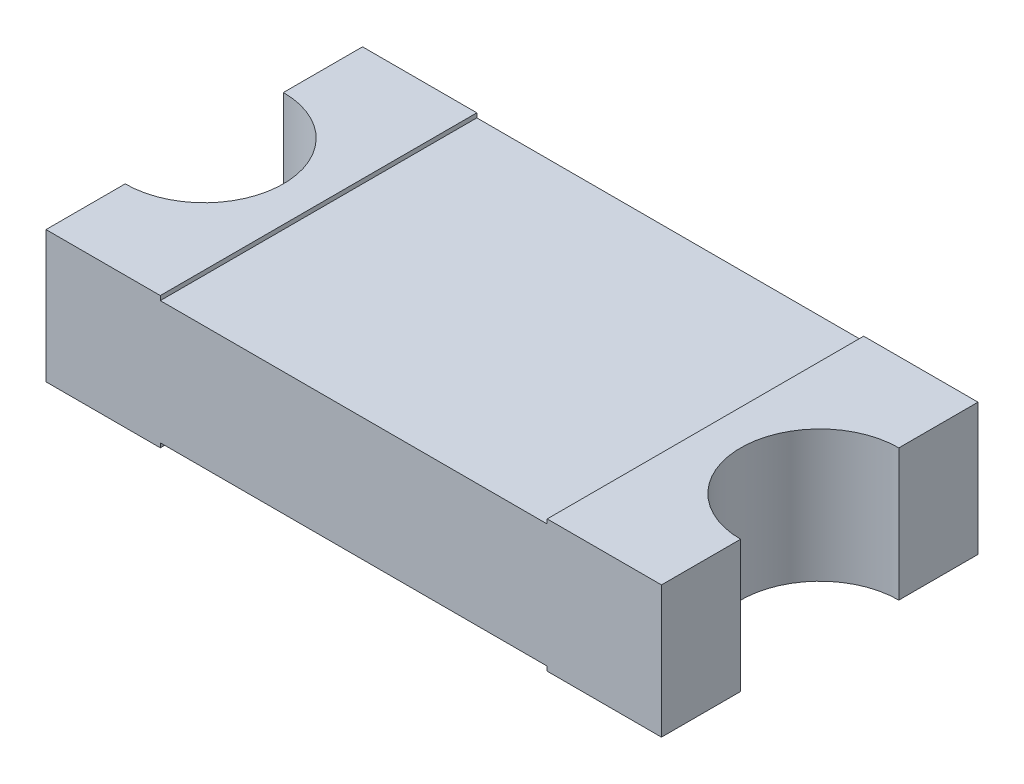
from build123d import *

# Parameters (mm, degrees)
BOSS_EXTRUDE1_DEPTH = 0.75
SKETCH2_W           = 2.2
SKETCH2_H           = 1.8
CUT_EXTRUDE1_DEPTH  = 0.025


with BuildPart() as part:
    # Sketch1 → Boss-Extrude1 (new body)
    with BuildSketch(Plane(origin=(0, 0, 0), x_dir=(1, 0, 0), z_dir=(0, 1, 0))):
        with BuildLine():
            Line((1.75, 0.45), (1.75, 0.9))
            Line((1.75, 0.9), (-1.75, 0.9))
            Line((-1.75, 0.9), (-1.75, 0.45))
            ThreePointArc((-1.75, 0.45), (-1.3, 0), (-1.75, -0.45))
            Line((-1.75, -0.45), (-1.75, -0.9))
            Line((-1.75, -0.9), (1.75, -0.9))
            Line((1.75, -0.9), (1.75, -0.45))
            ThreePointArc((1.75, -0.45), (1.3, 0), (1.75, 0.45))
        make_face()
    extrude(amount=BOSS_EXTRUDE1_DEPTH)

    # Sketch2 → Cut-Extrude1 (cut)
    with BuildSketch(Plane(origin=(0, 0.75, 0), x_dir=(1, 0, 0), z_dir=(0, 1, 0))):
        Rectangle(SKETCH2_W, SKETCH2_H)
    cut_extrude1 = extrude(amount=-CUT_EXTRUDE1_DEPTH, mode=Mode.SUBTRACT)

    # Mirror1: Cut-Extrude1 across plane
    add(cut_extrude1.mirror(Plane.ZX.offset(0.375)), mode=Mode.SUBTRACT)


solid = part.part
